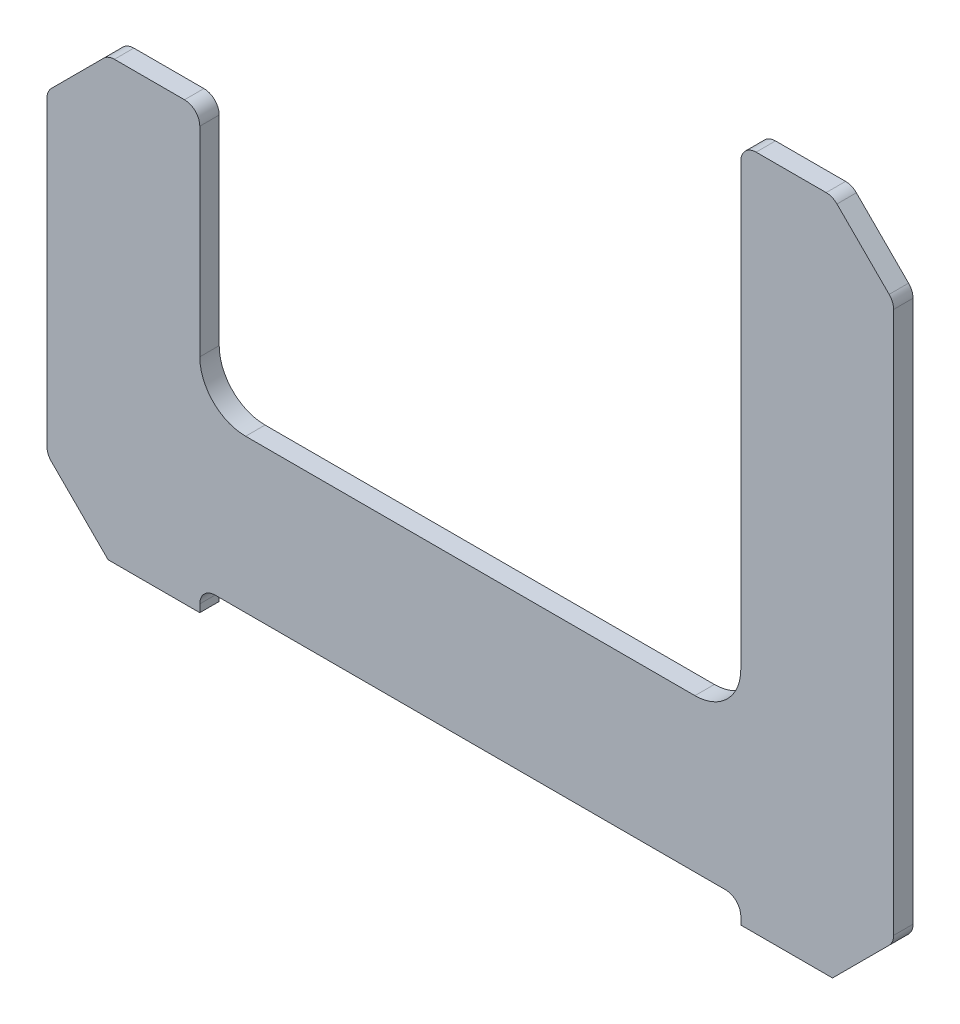
from build123d import *

# Parameters (mm, degrees)
BOSS_EXTRUDE1_DEPTH      = 3.175
BOSS_EXTRUDE1_DEPTH_BACK = 3.175
CHAMFER1_SIZE            = 20
FILLET1_R                = 15
FILLET2_R                = 5


with BuildPart() as part:
    # Sketch2 → Boss-Extrude1 (new body, two sides)
    with BuildSketch(Plane.XY) as boss_extrude1_sk:
        Polygon((-138.5, 85.338455572), (-88.5, 85.338455572), (-88.5, 0), (88.5, 0), (88.5, 164), (138.5, 164), (138.5, -57.5), (88.5, -57.5), (88.5, -50), (-88.5, -50), (-88.5, -57.5), (-138.5, -57.5), align=None)
    extrude(amount=BOSS_EXTRUDE1_DEPTH)
    extrude(boss_extrude1_sk.sketch, amount=-BOSS_EXTRUDE1_DEPTH_BACK)

    # Chamfer1
    chamfer1_edges = [part.edges().sort_by_distance(p)[0] for p in [
        (-138.5, 85.338455572, 0),
        (138.5, 164, 0),
        (138.5, -57.5, 0),
        (-138.5, -57.5, 0),
    ]]
    chamfer(chamfer1_edges, length=CHAMFER1_SIZE)

    # Fillet1
    fillet1_edges = [part.edges().sort_by_distance(p)[0] for p in [
        (-88.5, 0, 0),
        (88.5, 0, 0),
    ]]
    fillet(fillet1_edges, radius=FILLET1_R)

    # Fillet2
    fillet2_edges = [part.edges().sort_by_distance(p)[0] for p in [
        (-88.5, 85.338455572, 0),
        (88.5, 164, 0),
        (88.5, -50, 0),
        (-88.5, -50, 0),
        (-138.5, 65.338455572, 0),
        (-138.5, -37.5, 0),
        (138.5, 144, 0),
        (138.5, -37.5, 0),
        (118.5, 164, 0),
        (-118.5, 85.338455572, 0),
    ]]
    fillet(fillet2_edges, radius=FILLET2_R)


solid = part.part
